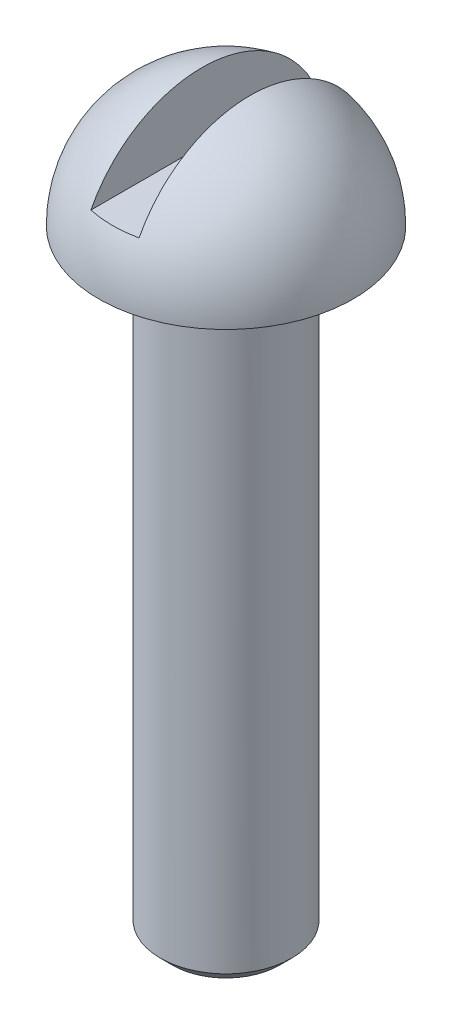
from build123d import *

# Parameters (mm, degrees)
CHAMFER_1_SIZE           = 0.2805
SKETCH_4_W               = 1.1
SKETCH_4_H               = 3.2
CUT_EXTRUDE_2_DEPTH      = 3.9
CUT_EXTRUDE_2_DEPTH_BACK = 3.9


with BuildPart() as part:
    # Эскиз1 → Повернуть1 (revolve)
    with BuildSketch(Plane.XY):
        with BuildLine():
            ThreePointArc((0, 2.9), (2.050609665, 2.050609665), (2.9, 0))
            Line((2.9, 0), (1.5, 0))
            Line((1.5, 0), (1.5, -14))
            Line((1.5, -14), (0, -14))
            Line((0, -14), (0, 2.9))
        make_face()
    revolve(axis=Axis((0, 2.9, 0), (0, -1, 0)))

    # Фаска1
    chamfer_1_edges = [part.edges().sort_by_distance(p)[0] for p in [
        (-1.5, -14, 0),
    ]]
    chamfer(chamfer_1_edges, length=CHAMFER_1_SIZE)

    # Эскиз4 → Вырез-Вытянуть2 (cut, two sides)
    with BuildSketch(Plane.XY) as cut_extrude_2_sk:
        with Locations((0, 2.9)):
            Rectangle(SKETCH_4_W, SKETCH_4_H)
    extrude(amount=CUT_EXTRUDE_2_DEPTH, mode=Mode.SUBTRACT)
    extrude(cut_extrude_2_sk.sketch, amount=-CUT_EXTRUDE_2_DEPTH_BACK, mode=Mode.SUBTRACT)


solid = part.part
